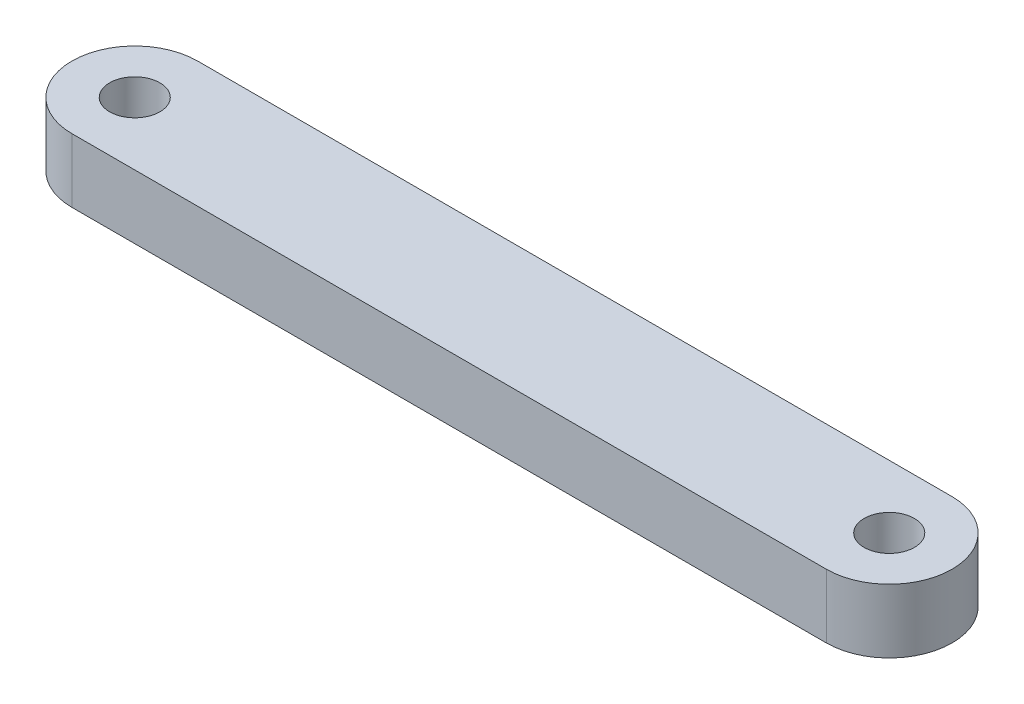
from build123d import *

# Parameters (mm, degrees)
BOSS_EXTRUDE1_DEPTH     = 2.54
SKETCH2_R               = 1
CUT_EXTRUDE1_DEPTH      = 3.54
CUT_EXTRUDE1_DEPTH_BACK = 1


with BuildPart() as part:
    # Sketch1 → Boss-Extrude1 (new body)
    with BuildSketch(Plane(origin=(0, 0, 0), x_dir=(1, 0, 0), z_dir=(0, 1, 0))):
        with BuildLine():
            Line((-15, 2.5), (15, 2.5))
            ThreePointArc((15, 2.5), (17.5, 0), (15, -2.5))
            Line((15, -2.5), (-15, -2.5))
            ThreePointArc((-15, -2.5), (-17.5, 0), (-15, 2.5))
        make_face()
    extrude(amount=BOSS_EXTRUDE1_DEPTH)

    # Sketch2 → Cut-Extrude1 (cut, two sides)
    with BuildSketch(Plane(origin=(0, 0, 0), x_dir=(1, 0, 0), z_dir=(0, 1, 0))) as cut_extrude1_sk:
        with Locations((-15, 0)):
            Circle(SKETCH2_R)
        with Locations((15, 0)):
            Circle(SKETCH2_R)
    extrude(amount=CUT_EXTRUDE1_DEPTH, mode=Mode.SUBTRACT)
    extrude(cut_extrude1_sk.sketch, amount=-CUT_EXTRUDE1_DEPTH_BACK, mode=Mode.SUBTRACT)


solid = part.part
